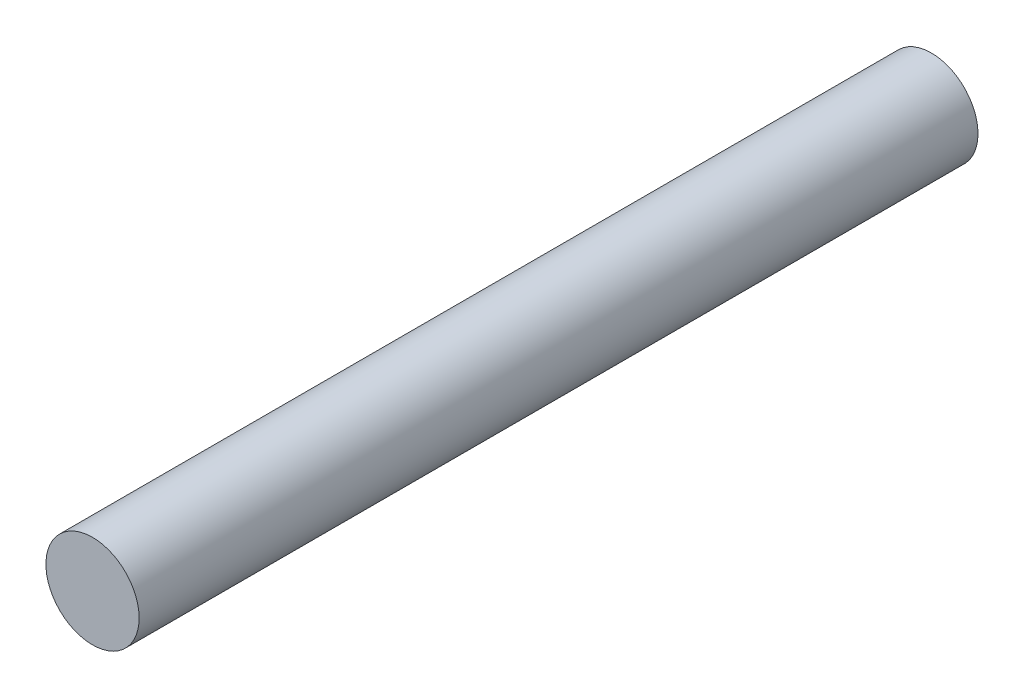
from build123d import *

# Parameters (mm, degrees)
SKETCH1_R           = 1
BOSS_EXTRUDE1_DEPTH = 9


with BuildPart() as part:
    # Sketch1 → Boss-Extrude1 (new body, symmetric)
    with BuildSketch(Plane.XY):
        Circle(SKETCH1_R)
    extrude(amount=BOSS_EXTRUDE1_DEPTH, both=True)


solid = part.part
